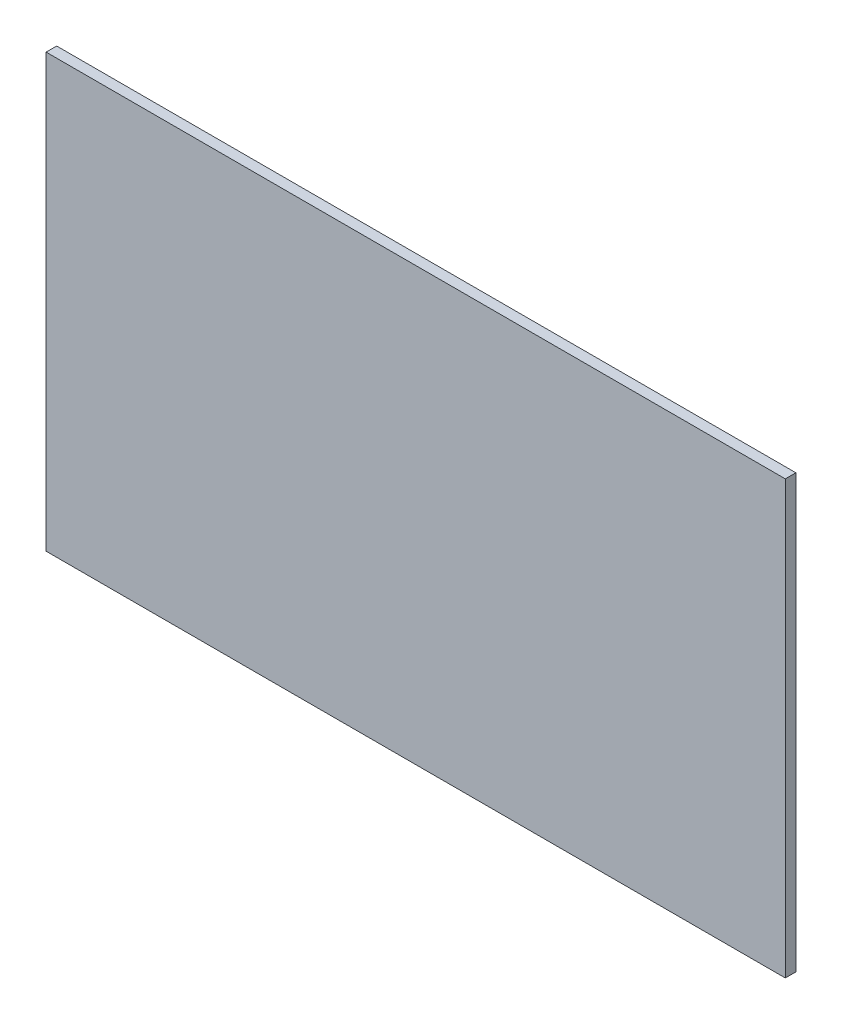
from build123d import *

# Parameters (mm, degrees)
SKETCH1_W           = 1400
SKETCH1_H           = 1400
BOSS_EXTRUDE1_DEPTH = 20
SKETCH3_W           = 1400
SKETCH3_H           = 581.306903256
CUT_EXTRUDE1_DEPTH  = 21


with BuildPart() as part:
    # Sketch1 → Boss-Extrude1 (new body)
    with BuildSketch(Plane.XY):
        with Locations((563.701923077, 625.240384615)):
            Rectangle(SKETCH1_W, SKETCH1_H)
    extrude(amount=BOSS_EXTRUDE1_DEPTH)

    # Sketch3 → Cut-Extrude1 (cut, through all)
    with BuildSketch(Plane(origin=(0, 0, 0), x_dir=(-1, 0, 0), z_dir=(0, 0, -1))):
        with Locations((-563.701923077, 215.893836243)):
            Rectangle(SKETCH3_W, SKETCH3_H)
    extrude(amount=-CUT_EXTRUDE1_DEPTH, mode=Mode.SUBTRACT)


solid = part.part
